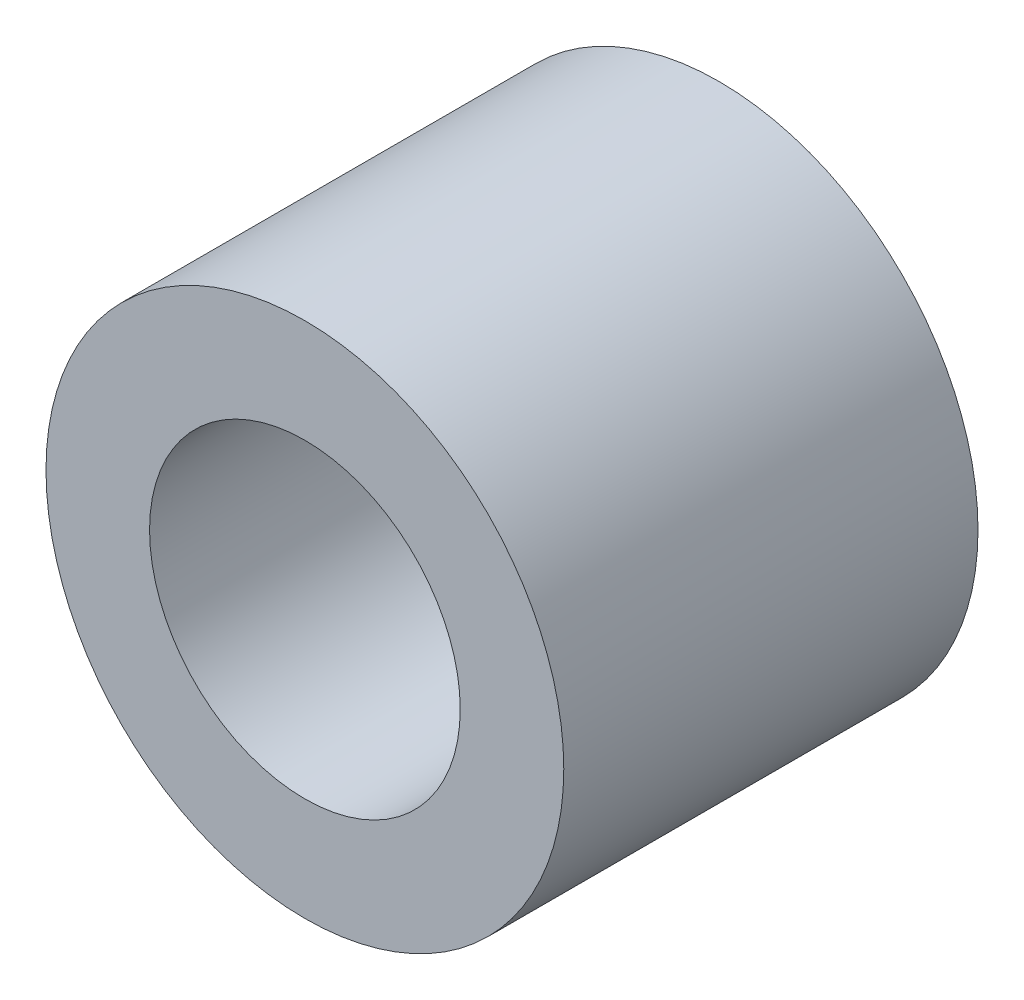
from build123d import *

# Parameters (mm, degrees)
SKETCH1_R           = 2.5
SKETCH1_R_2         = 1.5
BOSS_EXTRUDE1_DEPTH = 4


with BuildPart() as part:
    # Sketch1 → Boss-Extrude1 (new body)
    with BuildSketch(Plane.XY):
        Circle(SKETCH1_R)
        Circle(SKETCH1_R_2, mode=Mode.SUBTRACT)
    extrude(amount=BOSS_EXTRUDE1_DEPTH)


solid = part.part
